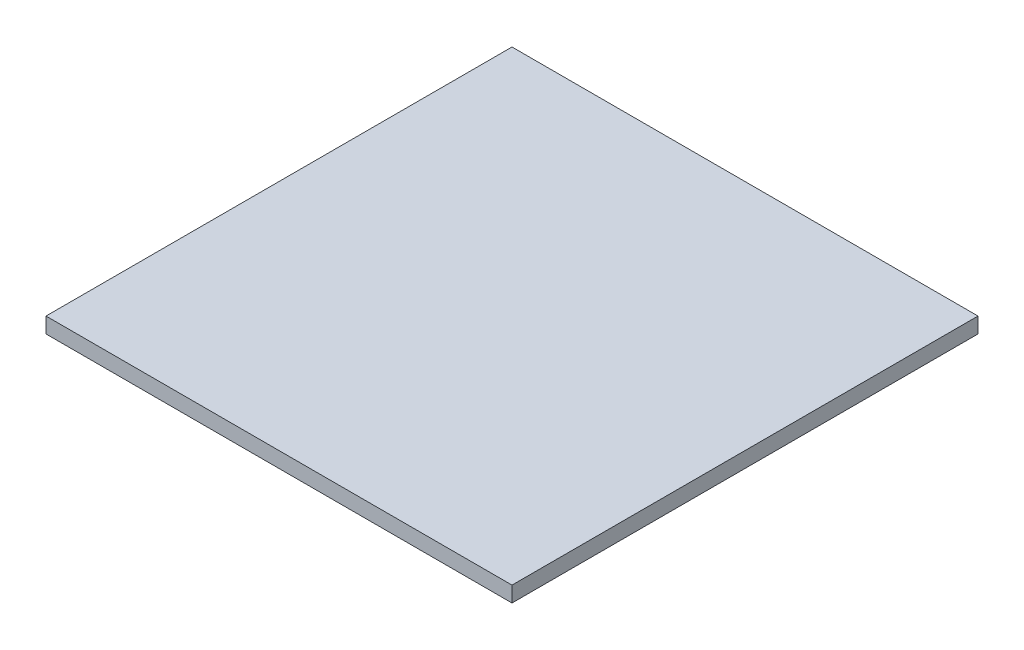
from build123d import *

# Parameters (mm, degrees)
SKETCH1_W           = 600
SKETCH1_H           = 600
BOSS_EXTRUDE1_DEPTH = 10


with BuildPart() as part:
    # Sketch1 → Boss-Extrude1 (new body, symmetric)
    with BuildSketch(Plane(origin=(0, 0, 0), x_dir=(1, 0, 0), z_dir=(0, 1, 0))):
        Rectangle(SKETCH1_W, SKETCH1_H)
    extrude(amount=BOSS_EXTRUDE1_DEPTH, both=True)


solid = part.part
